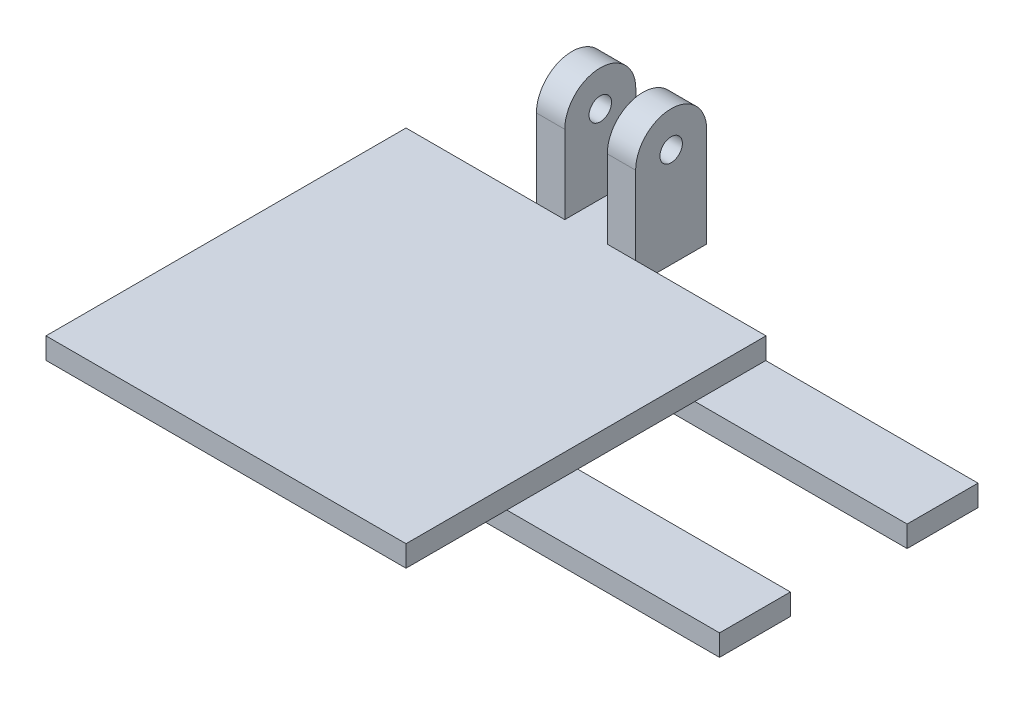
from build123d import *

# Parameters (mm, degrees)
BOSS_EXTRUDE1_DEPTH = 3
SKETCH1_3_W         = 4
SKETCH1_3_H         = 10.023203152
BOSS_EXTRUDE2_DEPTH = 19.05
SKETCH2_R           = 1.5875
CUT_EXTRUDE1_DEPTH  = 19.05
SKETCH3_W           = 80.796379589
SKETCH3_H           = 10
BOSS_EXTRUDE3_DEPTH = 3


with BuildPart() as part:
    # Sketch1 → Boss-Extrude1 (new body)
    with BuildSketch(Plane(origin=(0, 0, 0), x_dir=(1, 0, 0), z_dir=(0, 1, 0))):
        Polygon((0, 50.8), (0, 0), (50.8, 0), (50.8, 50.8), (28.4, 50.8), (28.4, 60.823203152), (22.4, 60.823203152), (22.4, 50.8), align=None)
    extrude(amount=BOSS_EXTRUDE1_DEPTH)

    # Sketch1_3 → Boss-Extrude2 (add)
    with BuildSketch(Plane(origin=(0, 0, 0), x_dir=(1, 0, 0), z_dir=(0, 1, 0))):
        with Locations((20.4, 55.811601576)):
            Rectangle(SKETCH1_3_W, SKETCH1_3_H)
        with Locations((30.4, 55.811601576)):
            Rectangle(SKETCH1_3_W, SKETCH1_3_H)
    extrude(amount=BOSS_EXTRUDE2_DEPTH)

    # Sketch2 → Cut-Extrude1 (cut)
    with BuildSketch(Plane(origin=(32.4, 0, 0), x_dir=(0, 0, -1), z_dir=(1, 0, 0))):
        with Locations((55.811601576, 14.038398424)):
            Circle(SKETCH2_R)
        with BuildLine():
            Line((50.8, 14.038398424), (49.911458456, 20.395059664))
            Line((49.911458456, 20.395059664), (64.501767063, 21.247740037))
            Line((64.501767063, 21.247740037), (60.823203152, 14.038398424))
            ThreePointArc((60.823203152, 14.038398424), (55.811601576, 19.05), (50.8, 14.038398424))
        make_face()
    extrude(amount=-CUT_EXTRUDE1_DEPTH, mode=Mode.SUBTRACT)

    # Sketch3 → Boss-Extrude3 (add)
    with BuildSketch(Plane.XZ):
        Polygon((30.017240132, -14.222777316), (0.017240132, -14.222777316), (0.017240132, -24.222777316), (80.817240132, -24.222777316), (80.817240132, -14.222777316), align=None)
        with Locations((40.354723884, -45.757439596)):
            Rectangle(SKETCH3_W, SKETCH3_H)
    extrude(amount=BOSS_EXTRUDE3_DEPTH)


solid = part.part
